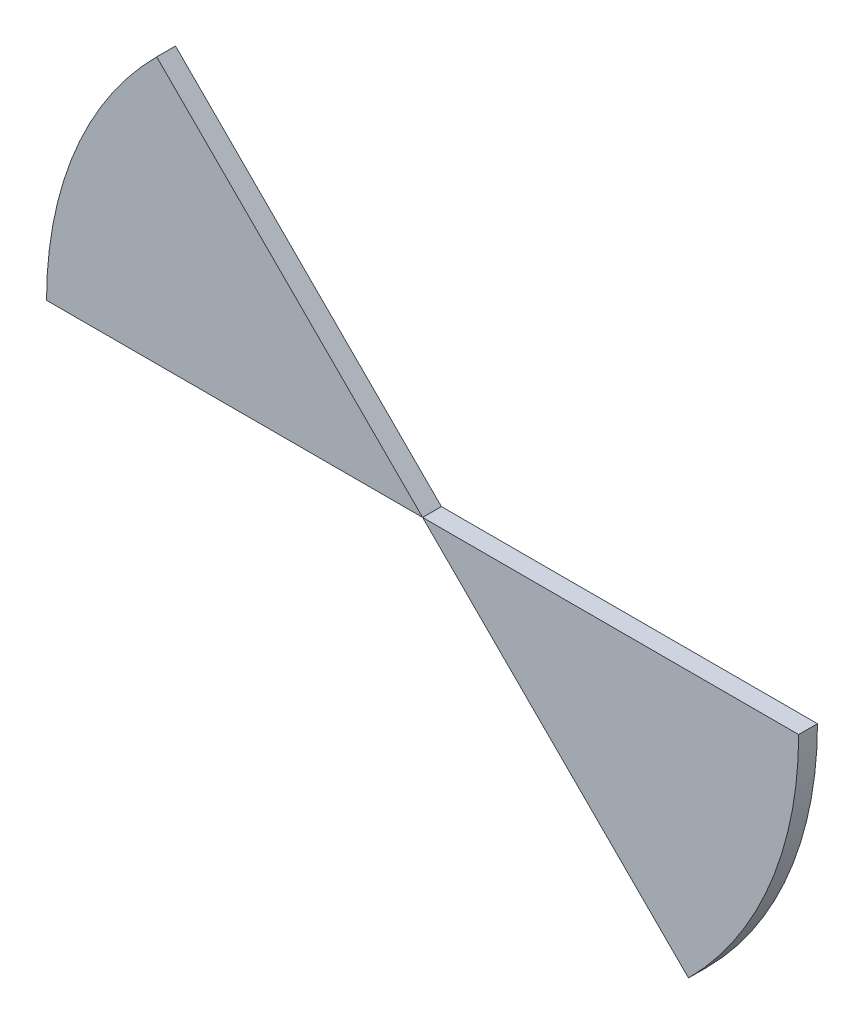
from build123d import *

# Parameters (mm, degrees)
BOSS_EXTRUDE1_DEPTH = 5
BOSS_EXTRUDE2_DEPTH = 5


with BuildPart() as part:
    # Sketch1 → Boss-Extrude1 (new body)
    with BuildSketch(Plane.XY):
        with BuildLine():
            Line((0, 0), (-70.710678119, 70.710678119))
            ThreePointArc((-70.710678119, 70.710678119), (-92.387953251, 38.268343237), (-100, 0))
            Line((-100, 0), (0, 0))
        make_face()
    extrude(amount=BOSS_EXTRUDE1_DEPTH)


with BuildPart() as body_2:
    # Sketch2 → Boss-Extrude2 (new body)
    with BuildSketch(Plane.XY):
        with BuildLine():
            Line((0, 0), (70.710678119, -70.710678119))
            ThreePointArc((70.710678119, -70.710678119), (92.387953251, -38.268343237), (100, 0))
            Line((100, 0), (0, 0))
        make_face()
    extrude(amount=BOSS_EXTRUDE2_DEPTH)


solid = Compound([part.part, body_2.part])
